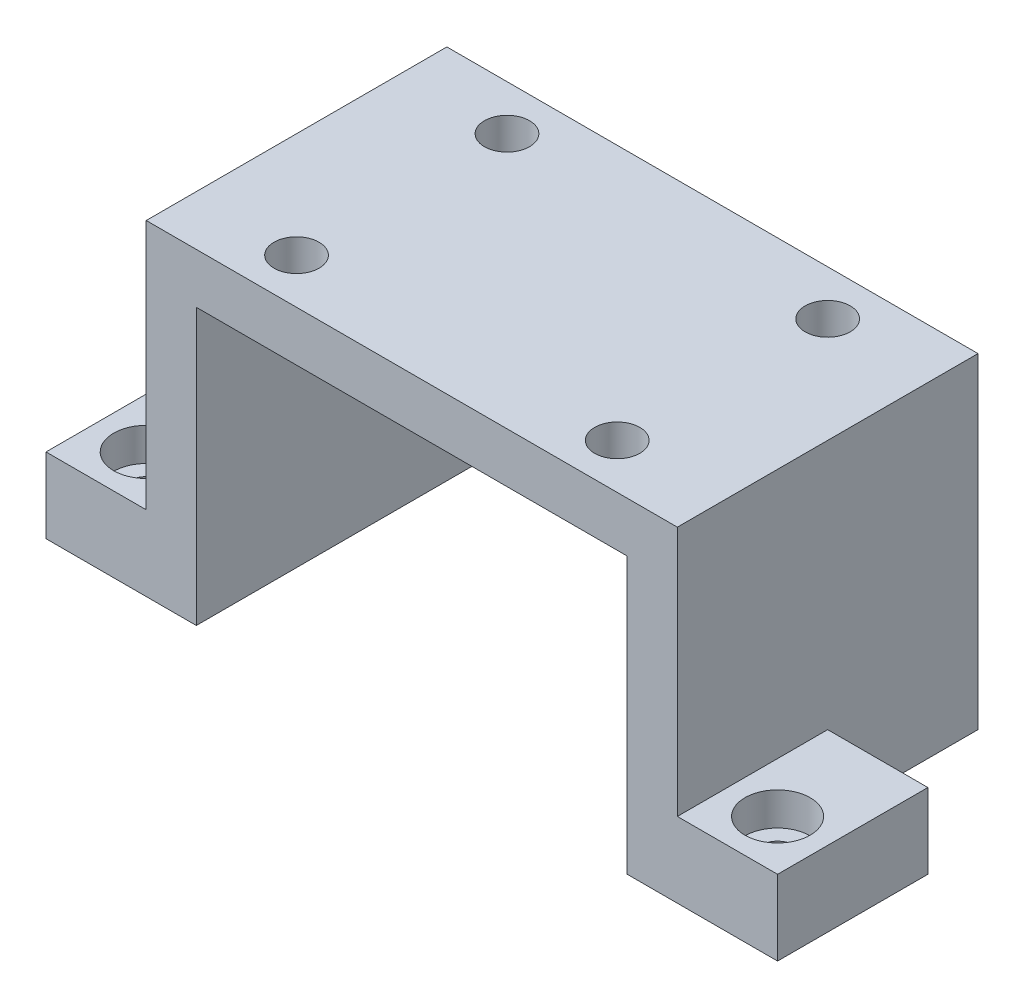
from build123d import *

# Parameters (mm, degrees)
SKETCH1_W           = 106
SKETCH1_H           = 60
BOSS_EXTRUDE1_DEPTH = 10
SKETCH2_W           = 10
SKETCH2_H           = 60
BOSS_EXTRUDE2_DEPTH = 55
SKETCH3_W           = 30
SKETCH3_H           = 15
BOSS_EXTRUDE3_DEPTH = 20
SKETCH4_W           = 60
SKETCH4_H           = 15
BOSS_EXTRUDE4_DEPTH = 20
SKETCH5_R           = 4.5
CUT_EXTRUDE1_DEPTH  = 66
SKETCH6_R           = 6.5
CUT_EXTRUDE2_DEPTH  = 6.6
SKETCH7_R           = 3.3
CUT_EXTRUDE3_DEPTH  = 9.4


with BuildPart() as part:
    # Sketch1 → Boss-Extrude1 (new body)
    with BuildSketch(Plane(origin=(0, 0, 0), x_dir=(1, 0, 0), z_dir=(0, 1, 0))):
        Rectangle(SKETCH1_W, SKETCH1_H)
    extrude(amount=BOSS_EXTRUDE1_DEPTH)

    # Sketch2 → Boss-Extrude2 (add)
    with BuildSketch(Plane.XZ):
        with Locations((-48, 0)):
            Rectangle(SKETCH2_W, SKETCH2_H)
        with Locations((48, 0)):
            Rectangle(SKETCH2_W, SKETCH2_H)
    extrude(amount=BOSS_EXTRUDE2_DEPTH)

    # Sketch3 → Boss-Extrude3 (add)
    with BuildSketch(Plane(origin=(53, 0, 0), x_dir=(0, 0, -1), z_dir=(1, 0, 0))):
        with Locations((-15, -47.5)):
            Rectangle(SKETCH3_W, SKETCH3_H)
    extrude(amount=BOSS_EXTRUDE3_DEPTH)

    # Sketch4 → Boss-Extrude4 (add)
    with BuildSketch(Plane.ZY.offset(53)):
        with Locations((0, -47.5)):
            Rectangle(SKETCH4_W, SKETCH4_H)
    extrude(amount=BOSS_EXTRUDE4_DEPTH)

    # Sketch5 → Cut-Extrude1 (cut, through all)
    with BuildSketch(Plane(origin=(0, 10, 0), x_dir=(1, 0, 0), z_dir=(0, 1, 0))):
        with Locations((-32, 21)):
            Circle(SKETCH5_R)
        with Locations((32, 21)):
            Circle(SKETCH5_R)
        with Locations((32, -21)):
            Circle(SKETCH5_R)
        with Locations((-32, -21)):
            Circle(SKETCH5_R)
    extrude(amount=-CUT_EXTRUDE1_DEPTH, mode=Mode.SUBTRACT)

    # Sketch6 → Cut-Extrude2 (cut)
    with BuildSketch(Plane(origin=(0, -40, 0), x_dir=(1, 0, 0), z_dir=(0, 1, 0))):
        with Locations((63, -20)):
            Circle(SKETCH6_R)
        with Locations((-63, 20)):
            Circle(SKETCH6_R)
        with Locations((-63, -20)):
            Circle(SKETCH6_R)
    extrude(amount=-CUT_EXTRUDE2_DEPTH, mode=Mode.SUBTRACT)

    # Sketch7 → Cut-Extrude3 (cut, through all)
    with BuildSketch(Plane(origin=(0, -46.6, 0), x_dir=(1, 0, 0), z_dir=(0, 1, 0))):
        with Locations((-63, 20)):
            Circle(SKETCH7_R)
        with Locations((-63, -20)):
            Circle(SKETCH7_R)
        with Locations((63, -20)):
            Circle(SKETCH7_R)
    extrude(amount=-CUT_EXTRUDE3_DEPTH, mode=Mode.SUBTRACT)


solid = part.part
